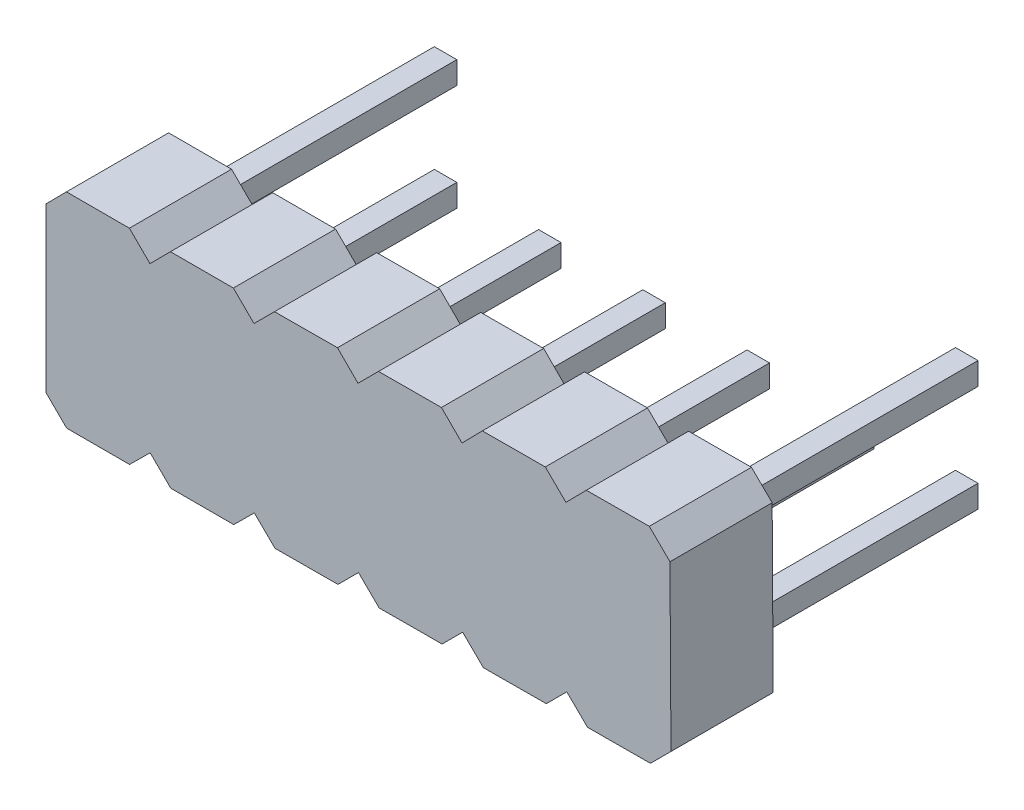
from build123d import *

# Parameters (mm, degrees)
BOSS_EXTRUDE1_DEPTH = 2.5
SKETCH2_W           = 0.55
SKETCH2_H           = 0.55
BOSS_EXTRUDE2_DEPTH = 6


with BuildPart() as part:
    # Sketch1 → Boss-Extrude1 (new body)
    with BuildSketch(Plane.XY):
        Polygon((0, 0), (0, 4), (0.5, 4.504083326), (2.04, 4.504083326), (2.544083326, 4.004083326), (3.044083326, 4.508166653), (4.584083326, 4.508166653), (5.088166653, 4.008166653), (5.590208299, 4.510216636), (7.130195513, 4.51649212), (7.632245496, 4.014450474), (8.134287142, 4.516500457), (9.674274356, 4.522775941), (10.176324339, 4.020734295), (10.674266053, 4.526850931), (12.214253267, 4.533126415), (12.720369903, 4.035184701), (13.218311617, 4.541301337), (14.758298831, 4.547576821), (15.264415467, 4.049635107), (15.28891529, 0.041535012), (14.786873643, -0.460514971), (13.24688643, -0.466790455), (12.740769794, 0.031151259), (12.238728147, -0.470898724), (10.698740934, -0.477174208), (10.192624298, 0.020767506), (9.690582651, -0.481282477), (8.150595438, -0.487557961), (7.644478802, 0.010383753), (7.142437155, -0.49166623), (5.602449942, -0.497941714), (5.096333306, 0), (4.592249979, -0.5), (3.052249979, -0.5), (2.548166653, 0), (2.044083326, -0.5), (0.504083326, -0.5), align=None)
    extrude(amount=BOSS_EXTRUDE1_DEPTH)

    # Sketch2 → Boss-Extrude2 (add)
    with BuildSketch(Plane.XY):
        with Locations((6.375, 0.705)):
            Rectangle(SKETCH2_W, SKETCH2_H)
        with Locations((3.825, 0.705)):
            Rectangle(SKETCH2_W, SKETCH2_H)
        with Locations((14.025, 0.705)):
            Rectangle(SKETCH2_W, SKETCH2_H)
        with Locations((14.025, 3.305)):
            Rectangle(SKETCH2_W, SKETCH2_H)
        with Locations((8.925, 0.705)):
            Rectangle(SKETCH2_W, SKETCH2_H)
        with Locations((1.275, 0.705)):
            Rectangle(SKETCH2_W, SKETCH2_H)
        with Locations((11.475, 0.705)):
            Rectangle(SKETCH2_W, SKETCH2_H)
        with Locations((1.275, 3.305)):
            Rectangle(SKETCH2_W, SKETCH2_H)
    extrude(amount=-BOSS_EXTRUDE2_DEPTH)


solid = part.part
